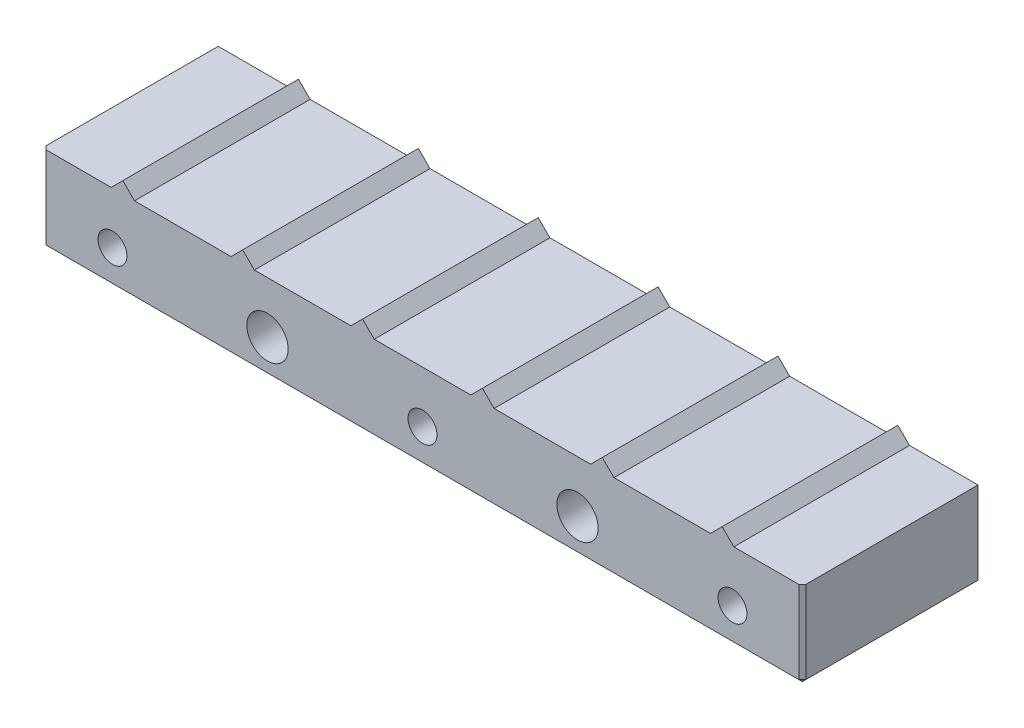
from build123d import *

# Parameters (mm, degrees)
EXTRUDE_1_DEPTH     = 25.5
M5X0_81_D           = 4.2
HOLE_WIZARD_6_0_1_D = 6
CHAMFER_1_SIZE      = 0.5


with BuildPart() as part:
    # Эскиз1 → Бобышка-Вытянуть1 (new body)
    with BuildSketch(Plane.XY):
        Polygon((110.285, 12.475), (110.285, 0), (0, 0), (0, 12.475), (9.956213203, 12.475), (11.65, 14.168786797), (13.343786797, 12.475), (27.356213203, 12.475), (29.05, 14.168786797), (30.743786797, 12.475), (44.756213203, 12.475), (46.45, 14.168786797), (48.143786797, 12.475), (62.156213203, 12.475), (63.85, 14.168786797), (65.543786797, 12.475), (79.556213203, 12.475), (81.25, 14.168786797), (82.943786797, 12.475), (96.956213203, 12.475), (98.65, 14.168786797), (100.343786797, 12.475), align=None)
    extrude(amount=-EXTRUDE_1_DEPTH)

    # Отверстие обработанное метчиком M5x0.81 (through all)
    with Locations(Plane(origin=(-77.729263736, 6.808390477, 0), x_dir=(1, 0, 0), z_dir=(0, 0, 1))):
        with Locations((132.879263736, -1.818390477), (87.879263736, -1.818390477), (177.879263736, -1.818390477)):
            Hole(M5X0_81_D / 2)

    # Отверстия под штифты Ø6.0 мм1 (through all)
    with Locations(Plane.XY):
        with Locations((32.65, 4.99), (77.65, 4.99)):
            Hole(HOLE_WIZARD_6_0_1_D / 2)

    # Фаска1
    chamfer_1_edges = [part.edges().sort_by_distance(p)[0] for p in [
        (0, 6.2375, 0),
        (55.1425, 0, 0),
        (110.285, 6.2375, 0),
        (0, 0, -12.75),
        (110.285, 0, -12.75),
        (55.1425, 0, -25.5),
    ]]
    chamfer(chamfer_1_edges, length=CHAMFER_1_SIZE)


solid = part.part
